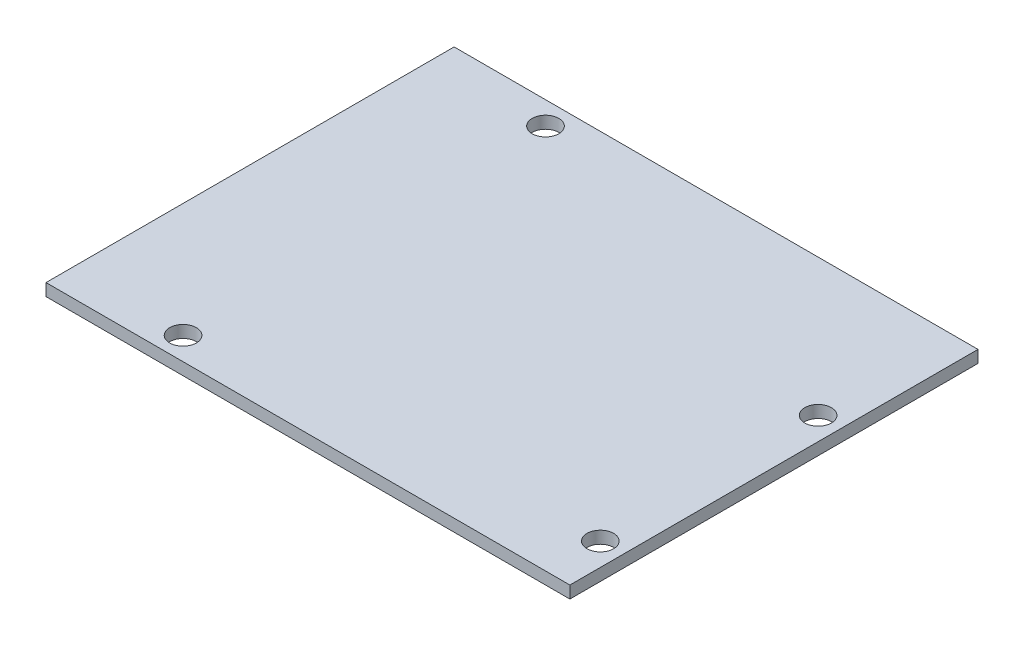
from build123d import *

# Parameters (mm, degrees)
SKETCH1_W           = 68.8
SKETCH1_H           = 53.6
BOSS_EXTRUDE1_DEPTH = 1.6
CUT_EXTRUDE1_REACH  = 3.6
SKETCH2_R           = 1.75


with BuildPart() as part:
    # Sketch1 → Boss-Extrude1 (new body)
    with BuildSketch(Plane(origin=(0, 0, 0), x_dir=(-1, 0, 0), z_dir=(0, 1, 0))):
        Rectangle(SKETCH1_W, SKETCH1_H)
    extrude(amount=BOSS_EXTRUDE1_DEPTH)

    # Sketch2 → Cut-Extrude1 (cut, up to next)
    with BuildSketch(Plane(origin=(0, 1.6, 0), x_dir=(-1, 0, 0), z_dir=(0, 1, 0)), mode=Mode.PRIVATE) as cut_extrude1_sk1:
        with Locations((19.4, -23.8)):
            Circle(SKETCH2_R)
    cut_extrude1_tool1 = extrude(cut_extrude1_sk1.sketch, amount=-CUT_EXTRUDE1_REACH, mode=Mode.PRIVATE) & part.part
    add(cut_extrude1_tool1.solids().sort_by_distance((-19.4, 1.6, -23.8))[0], mode=Mode.SUBTRACT)
    # Sketch2 → Cut-Extrude1 (cut, up to next)
    with BuildSketch(Plane(origin=(0, 1.6, 0), x_dir=(-1, 0, 0), z_dir=(0, 1, 0)), mode=Mode.PRIVATE) as cut_extrude1_sk2:
        with Locations((19.4, 23.8)):
            Circle(SKETCH2_R)
    cut_extrude1_tool2 = extrude(cut_extrude1_sk2.sketch, amount=-CUT_EXTRUDE1_REACH, mode=Mode.PRIVATE) & part.part
    add(cut_extrude1_tool2.solids().sort_by_distance((-19.4, 1.6, 23.8))[0], mode=Mode.SUBTRACT)
    # Sketch2 → Cut-Extrude1 (cut, up to next)
    with BuildSketch(Plane(origin=(0, 1.6, 0), x_dir=(-1, 0, 0), z_dir=(0, 1, 0)), mode=Mode.PRIVATE) as cut_extrude1_sk3:
        with Locations((-31.4, 19.8)):
            Circle(SKETCH2_R)
    cut_extrude1_tool3 = extrude(cut_extrude1_sk3.sketch, amount=-CUT_EXTRUDE1_REACH, mode=Mode.PRIVATE) & part.part
    add(cut_extrude1_tool3.solids().sort_by_distance((31.4, 1.6, 19.8))[0], mode=Mode.SUBTRACT)
    # Sketch2 → Cut-Extrude1 (cut, up to next)
    with BuildSketch(Plane(origin=(0, 1.6, 0), x_dir=(-1, 0, 0), z_dir=(0, 1, 0)), mode=Mode.PRIVATE) as cut_extrude1_sk4:
        with Locations((-31.4, -8.8)):
            Circle(SKETCH2_R)
    cut_extrude1_tool4 = extrude(cut_extrude1_sk4.sketch, amount=-CUT_EXTRUDE1_REACH, mode=Mode.PRIVATE) & part.part
    add(cut_extrude1_tool4.solids().sort_by_distance((31.4, 1.6, -8.8))[0], mode=Mode.SUBTRACT)


solid = part.part
